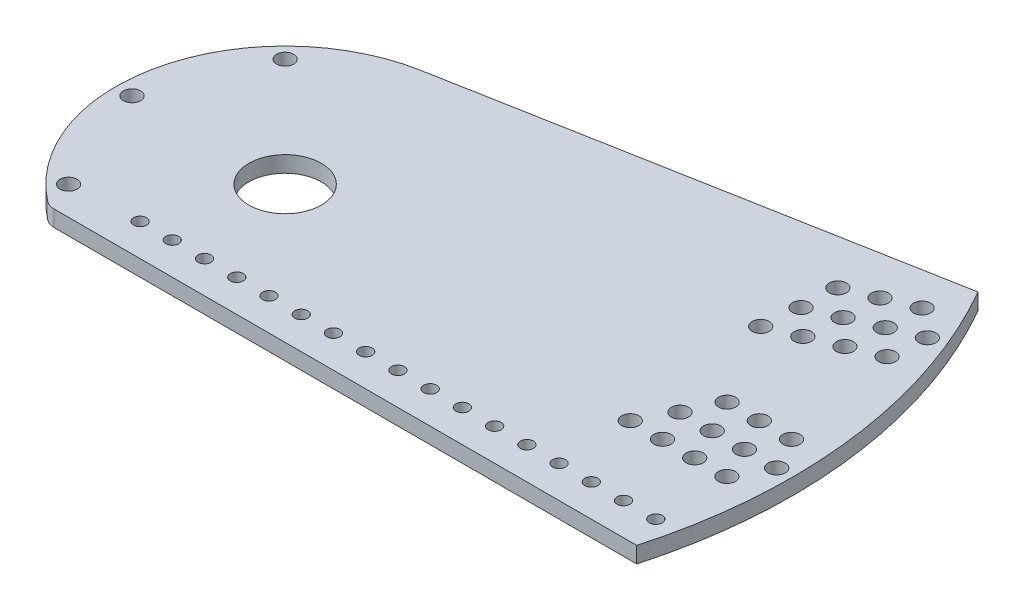
from build123d import *

# Parameters (mm, degrees)
SKETCH1_R           = 3.3782
SKETCH1_R_2         = 14.28115
SKETCH1_R_3         = 2.5527
SKETCH1_R_4         = 9.5885
SKETCH1_R_5         = 19.177
SKETCH1_R_6         = 4.1275
BOSS_EXTRUDE1_DEPTH = 6.35
SKETCH2_R           = 19.177
SKETCH2_R_2         = 2.5527
SKETCH2_R_3         = 4.1275
SKETCH2_R_4         = 9.5885
BOSS_EXTRUDE2_DEPTH = 6.35
CUT_EXTRUDE1_DEPTH  = 337.819467594
BOSS_EXTRUDE3_DEPTH = 6.35


with BuildPart() as part:
    # Sketch1 → Boss-Extrude1 (new body)
    with BuildSketch(Plane.XZ):
        with BuildLine():
            Line((231.775, 53.975), (-37.026544532, 53.975))
            ThreePointArc((-37.026544532, 53.975), (-39.086756581, 53.631498674), (-40.924075536, 52.638157895))
            ThreePointArc((-40.924075536, 52.638157895), (-66.304119268, -7.022776738), (-28.989130435, -60.043200628))
            ThreePointArc((-28.989130435, -60.043200628), (-26.371616333, -62.385880153), (-25.4, -65.761600688))
            Line((-25.4, -65.761600688), (-25.4, -230.990796624))
            ThreePointArc((-25.4, -230.990796624), (-23.721010495, -235.292442932), (-19.571917808, -237.3193116))
            ThreePointArc((-19.571917808, -237.3193116), (161.311736549, -175.162893549), (238.125, 0))
            Line((238.125, 0), (238.125, 47.625))
            ThreePointArc((238.125, 47.625), (236.265128061, 52.115128061), (231.775, 53.975))
        make_face()
        with Locations(Location((-60.325, 0, 0), (0, 0, 90))):
            Circle(SKETCH1_R, mode=Mode.SUBTRACT)
        with Locations(Location((-42.656216575, 42.656216575, 0), (0, 0, 90))):
            Circle(SKETCH1_R, mode=Mode.SUBTRACT)
        with Locations(Location((-42.656216575, -42.656216575, 0), (0, 0, 90))):
            Circle(SKETCH1_R, mode=Mode.SUBTRACT)
        with Locations(Location((0, -155.575, 0), (0, 0, 90))):
            Circle(SKETCH1_R, mode=Mode.SUBTRACT)
        with Locations(Location((0, -168.275, 0), (0, 0, 90))):
            Circle(SKETCH1_R, mode=Mode.SUBTRACT)
        with Locations(Location((0, -180.975, 0), (0, 0, 90))):
            Circle(SKETCH1_R, mode=Mode.SUBTRACT)
        with Locations(Location((0, -193.675, 0), (0, 0, 90))):
            Circle(SKETCH1_R, mode=Mode.SUBTRACT)
        with Locations(Location((0, -206.375, 0), (0, 0, 90))):
            Circle(SKETCH1_R, mode=Mode.SUBTRACT)
        with Locations(Location((0, -219.075, 0), (0, 0, 90))):
            Circle(SKETCH1_R, mode=Mode.SUBTRACT)
        with Locations(Location((59.53597499, -143.73255827, 0), (0, 0, 90))):
            Circle(SKETCH1_R, mode=Mode.SUBTRACT)
        with Locations(Location((64.396054581, -155.465828333, 0), (0, 0, 90))):
            Circle(SKETCH1_R, mode=Mode.SUBTRACT)
        with Locations(Location((69.256134172, -167.199098396, 0), (0, 0, 90))):
            Circle(SKETCH1_R, mode=Mode.SUBTRACT)
        with Locations(Location((74.116213763, -178.932368459, 0), (0, 0, 90))):
            Circle(SKETCH1_R, mode=Mode.SUBTRACT)
        with Locations(Location((78.976293354, -190.665638522, 0), (0, 0, 90))):
            Circle(SKETCH1_R, mode=Mode.SUBTRACT)
        with Locations(Location((83.836372945, -202.398908585, 0), (0, 0, 90))):
            Circle(SKETCH1_R, mode=Mode.SUBTRACT)
        with Locations(Location((110.008137483, -110.008137483, 0), (0, 0, 90))):
            Circle(SKETCH1_R, mode=Mode.SUBTRACT)
        with Locations(Location((118.988393604, -118.988393604, 0), (0, 0, 90))):
            Circle(SKETCH1_R, mode=Mode.SUBTRACT)
        with Locations(Location((127.968649725, -127.968649725, 0), (0, 0, 90))):
            Circle(SKETCH1_R, mode=Mode.SUBTRACT)
        with Locations(Location((136.948905846, -136.948905846, 0), (0, 0, 90))):
            Circle(SKETCH1_R, mode=Mode.SUBTRACT)
        with Locations(Location((145.929161967, -145.929161967, 0), (0, 0, 90))):
            Circle(SKETCH1_R, mode=Mode.SUBTRACT)
        with Locations(Location((154.909418088, -154.909418088, 0), (0, 0, 90))):
            Circle(SKETCH1_R, mode=Mode.SUBTRACT)
        with Locations(Location((143.73255827, -59.53597499, 0), (0, 0, 90))):
            Circle(SKETCH1_R, mode=Mode.SUBTRACT)
        with Locations(Location((155.465828333, -64.396054581, 0), (0, 0, 90))):
            Circle(SKETCH1_R, mode=Mode.SUBTRACT)
        with Locations(Location((167.199098396, -69.256134172, 0), (0, 0, 90))):
            Circle(SKETCH1_R, mode=Mode.SUBTRACT)
        with Locations(Location((178.932368459, -74.116213763, 0), (0, 0, 90))):
            Circle(SKETCH1_R, mode=Mode.SUBTRACT)
        with Locations(Location((190.665638522, -78.976293354, 0), (0, 0, 90))):
            Circle(SKETCH1_R, mode=Mode.SUBTRACT)
        with Locations(Location((202.398908585, -83.836372945, 0), (0, 0, 90))):
            Circle(SKETCH1_R, mode=Mode.SUBTRACT)
        with Locations(Location((155.575, 0, 0), (0, 0, 90))):
            Circle(SKETCH1_R, mode=Mode.SUBTRACT)
        with Locations(Location((168.275, 0, 0), (0, 0, 90))):
            Circle(SKETCH1_R, mode=Mode.SUBTRACT)
        with Locations(Location((180.975, 0, 0), (0, 0, 90))):
            Circle(SKETCH1_R, mode=Mode.SUBTRACT)
        with Locations(Location((193.675, 0, 0), (0, 0, 90))):
            Circle(SKETCH1_R, mode=Mode.SUBTRACT)
        with Locations(Location((206.375, 0, 0), (0, 0, 90))):
            Circle(SKETCH1_R, mode=Mode.SUBTRACT)
        with Locations(Location((219.075, 0, 0), (0, 0, 90))):
            Circle(SKETCH1_R, mode=Mode.SUBTRACT)
        with Locations(Location((0, 0, 0), (0, 0, 90))):
            Circle(SKETCH1_R_2, mode=Mode.SUBTRACT)
        with Locations(Location((148.683592319, 12.7, 0), (0, 0, 90))):
            Circle(SKETCH1_R, mode=Mode.SUBTRACT)
        with Locations(Location((141.086323741, -159.046835983, 0), (0, 0, 90))):
            Circle(SKETCH1_R, mode=Mode.SUBTRACT)
        with Locations(Location((150.036456986, -132.075944743, 0), (0, 0, 90))):
            Circle(SKETCH1_R, mode=Mode.SUBTRACT)
        with Locations(Location((150.066579862, -168.027092104, 0), (0, 0, 90))):
            Circle(SKETCH1_R, mode=Mode.SUBTRACT)
        with Locations(Location((159.016713107, -141.056200864, 0), (0, 0, 90))):
            Circle(SKETCH1_R, mode=Mode.SUBTRACT)
        with Locations(Location((-12.7, -186.8261925, 0), (0, 0, 90))):
            Circle(SKETCH1_R, mode=Mode.SUBTRACT)
        with Locations(Location((12.7, -174.083592319, 0), (0, 0, 90))):
            Circle(SKETCH1_R, mode=Mode.SUBTRACT)
        with Locations(Location((-12.7, -199.5261925, 0), (0, 0, 90))):
            Circle(SKETCH1_R, mode=Mode.SUBTRACT)
        with Locations(Location((12.7, -186.783592319, 0), (0, 0, 90))):
            Circle(SKETCH1_R, mode=Mode.SUBTRACT)
        with Locations(Location((-12.7, -212.2261925, 0), (0, 0, 90))):
            Circle(SKETCH1_R, mode=Mode.SUBTRACT)
        with Locations(Location((12.7, -199.483592319, 0), (0, 0, 90))):
            Circle(SKETCH1_R, mode=Mode.SUBTRACT)
        with Locations(Location((-12.7, -224.9261925, 0), (0, 0, 90))):
            Circle(SKETCH1_R, mode=Mode.SUBTRACT)
        with Locations(Location((12.7, -212.183592319, 0), (0, 0, 90))):
            Circle(SKETCH1_R, mode=Mode.SUBTRACT)
        with Locations(Location((69.482177721, -200.931515104, 0), (0, 0, 90))):
            Circle(SKETCH1_R, mode=Mode.SUBTRACT)
        with Locations(Location((88.072335872, -179.438728425, 0), (0, 0, 90))):
            Circle(SKETCH1_R, mode=Mode.SUBTRACT)
        with Locations(Location((74.342257312, -212.664785167, 0), (0, 0, 90))):
            Circle(SKETCH1_R, mode=Mode.SUBTRACT)
        with Locations(Location((92.932415463, -191.171998488, 0), (0, 0, 90))):
            Circle(SKETCH1_R, mode=Mode.SUBTRACT)
        with Locations(Location((50.041859357, -153.998434853, 0), (0, 0, 90))):
            Circle(SKETCH1_R, mode=Mode.SUBTRACT)
        with Locations(Location((68.632017508, -132.505648173, 0), (0, 0, 90))):
            Circle(SKETCH1_R, mode=Mode.SUBTRACT)
        with Locations(Location((54.901938948, -165.731704916, 0), (0, 0, 90))):
            Circle(SKETCH1_R, mode=Mode.SUBTRACT)
        with Locations(Location((73.492097099, -144.238918236, 0), (0, 0, 90))):
            Circle(SKETCH1_R, mode=Mode.SUBTRACT)
        with Locations(Location((59.762018539, -177.464974979, 0), (0, 0, 90))):
            Circle(SKETCH1_R, mode=Mode.SUBTRACT)
        with Locations(Location((78.35217669, -155.972188299, 0), (0, 0, 90))):
            Circle(SKETCH1_R, mode=Mode.SUBTRACT)
        with Locations(Location((64.62209813, -189.198245042, 0), (0, 0, 90))):
            Circle(SKETCH1_R, mode=Mode.SUBTRACT)
        with Locations(Location((83.212256281, -167.705458362, 0), (0, 0, 90))):
            Circle(SKETCH1_R, mode=Mode.SUBTRACT)
        with Locations(Location((123.125811499, -141.086323741, 0), (0, 0, 90))):
            Circle(SKETCH1_R, mode=Mode.SUBTRACT)
        with Locations(Location((132.075944743, -114.115432501, 0), (0, 0, 90))):
            Circle(SKETCH1_R, mode=Mode.SUBTRACT)
        with Locations(Location((132.10606762, -150.066579862, 0), (0, 0, 90))):
            Circle(SKETCH1_R, mode=Mode.SUBTRACT)
        with Locations(Location((141.056200864, -123.095688622, 0), (0, 0, 90))):
            Circle(SKETCH1_R, mode=Mode.SUBTRACT)
        with Locations(Location((200.89215767, -69.465875337, 0), (0, 0, 90))):
            Circle(SKETCH1_R, mode=Mode.SUBTRACT)
        with Locations(Location((202.944625985, -97.808797438, 0), (0, 0, 90))):
            Circle(SKETCH1_R, mode=Mode.SUBTRACT)
        with Locations(Location((189.158887607, -64.605795746, 0), (0, 0, 90))):
            Circle(SKETCH1_R, mode=Mode.SUBTRACT)
        with Locations(Location((191.211355922, -92.948717847, 0), (0, 0, 90))):
            Circle(SKETCH1_R, mode=Mode.SUBTRACT)
        with Locations(Location((105.165299257, -123.125811499, 0), (0, 0, 90))):
            Circle(SKETCH1_R, mode=Mode.SUBTRACT)
        with Locations(Location((114.115432501, -96.154920259, 0), (0, 0, 90))):
            Circle(SKETCH1_R, mode=Mode.SUBTRACT)
        with Locations(Location((114.145555378, -132.10606762, 0), (0, 0, 90))):
            Circle(SKETCH1_R, mode=Mode.SUBTRACT)
        with Locations(Location((123.095688622, -105.13517638, 0), (0, 0, 90))):
            Circle(SKETCH1_R, mode=Mode.SUBTRACT)
        with Locations(Location((153.959077418, -50.025556973, 0), (0, 0, 90))):
            Circle(SKETCH1_R, mode=Mode.SUBTRACT)
        with Locations(Location((156.011545734, -78.368479073, 0), (0, 0, 90))):
            Circle(SKETCH1_R, mode=Mode.SUBTRACT)
        with Locations(Location((142.225807355, -45.165477382, 0), (0, 0, 90))):
            Circle(SKETCH1_R, mode=Mode.SUBTRACT)
        with Locations(Location((144.278275671, -73.508399482, 0), (0, 0, 90))):
            Circle(SKETCH1_R, mode=Mode.SUBTRACT)
        with Locations(Location((177.425617544, -59.745716155, 0), (0, 0, 90))):
            Circle(SKETCH1_R, mode=Mode.SUBTRACT)
        with Locations(Location((179.478085859, -88.088638255, 0), (0, 0, 90))):
            Circle(SKETCH1_R, mode=Mode.SUBTRACT)
        with Locations(Location((165.692347481, -54.885636564, 0), (0, 0, 90))):
            Circle(SKETCH1_R, mode=Mode.SUBTRACT)
        with Locations(Location((167.744815797, -83.228558664, 0), (0, 0, 90))):
            Circle(SKETCH1_R, mode=Mode.SUBTRACT)
        with Locations(Location((-12.7, -161.4261925, 0), (0, 0, 90))):
            Circle(SKETCH1_R, mode=Mode.SUBTRACT)
        with Locations(Location((12.7, -148.683592319, 0), (0, 0, 90))):
            Circle(SKETCH1_R, mode=Mode.SUBTRACT)
        with Locations(Location((-12.7, -174.1261925, 0), (0, 0, 90))):
            Circle(SKETCH1_R, mode=Mode.SUBTRACT)
        with Locations(Location((12.7, -161.383592319, 0), (0, 0, 90))):
            Circle(SKETCH1_R, mode=Mode.SUBTRACT)
        with Locations(Location((186.8261925, -12.7, 0), (0, 0, 90))):
            Circle(SKETCH1_R, mode=Mode.SUBTRACT)
        with Locations(Location((174.083592319, 12.7, 0), (0, 0, 90))):
            Circle(SKETCH1_R, mode=Mode.SUBTRACT)
        with Locations(Location((199.5261925, -12.7, 0), (0, 0, 90))):
            Circle(SKETCH1_R, mode=Mode.SUBTRACT)
        with Locations(Location((186.783592319, 12.7, 0), (0, 0, 90))):
            Circle(SKETCH1_R, mode=Mode.SUBTRACT)
        with Locations(Location((212.2261925, -12.7, 0), (0, 0, 90))):
            Circle(SKETCH1_R, mode=Mode.SUBTRACT)
        with Locations(Location((199.483592319, 12.7, 0), (0, 0, 90))):
            Circle(SKETCH1_R, mode=Mode.SUBTRACT)
        with Locations(Location((224.9261925, -12.7, 0), (0, 0, 90))):
            Circle(SKETCH1_R, mode=Mode.SUBTRACT)
        with Locations(Location((212.183592319, 12.7, 0), (0, 0, 90))):
            Circle(SKETCH1_R, mode=Mode.SUBTRACT)
        with Locations(Location((161.4261925, -12.7, 0), (0, 0, 90))):
            Circle(SKETCH1_R, mode=Mode.SUBTRACT)
        with Locations(Location((174.1261925, -12.7, 0), (0, 0, 90))):
            Circle(SKETCH1_R, mode=Mode.SUBTRACT)
        with Locations(Location((161.383592319, 12.7, 0), (0, 0, 90))):
            Circle(SKETCH1_R, mode=Mode.SUBTRACT)
        with Locations(Location((225.425, 41.275, 0), (0, 0, 90))):
            Circle(SKETCH1_R_3, mode=Mode.SUBTRACT)
        with Locations(Location((212.725, 41.275, 0), (0, 0, 90))):
            Circle(SKETCH1_R_3, mode=Mode.SUBTRACT)
        with Locations(Location((200.025, 41.275, 0), (0, 0, 90))):
            Circle(SKETCH1_R_3, mode=Mode.SUBTRACT)
        with Locations(Location((187.325, 41.275, 0), (0, 0, 90))):
            Circle(SKETCH1_R_3, mode=Mode.SUBTRACT)
        with Locations(Location((174.625, 41.275, 0), (0, 0, 90))):
            Circle(SKETCH1_R_3, mode=Mode.SUBTRACT)
        with Locations(Location((161.925, 41.275, 0), (0, 0, 90))):
            Circle(SKETCH1_R_3, mode=Mode.SUBTRACT)
        with Locations(Location((149.225, 41.275, 0), (0, 0, 90))):
            Circle(SKETCH1_R_3, mode=Mode.SUBTRACT)
        with Locations(Location((136.525, 41.275, 0), (0, 0, 90))):
            Circle(SKETCH1_R_3, mode=Mode.SUBTRACT)
        with Locations(Location((123.825, 41.275, 0), (0, 0, 90))):
            Circle(SKETCH1_R_3, mode=Mode.SUBTRACT)
        with Locations(Location((111.125, 41.275, 0), (0, 0, 90))):
            Circle(SKETCH1_R_3, mode=Mode.SUBTRACT)
        with Locations(Location((98.425, 41.275, 0), (0, 0, 90))):
            Circle(SKETCH1_R_3, mode=Mode.SUBTRACT)
        with Locations(Location((73.025, 41.275, 0), (0, 0, 90))):
            Circle(SKETCH1_R_3, mode=Mode.SUBTRACT)
        with Locations(Location((85.725, 41.275, 0), (0, 0, 90))):
            Circle(SKETCH1_R_3, mode=Mode.SUBTRACT)
        with Locations(Location((60.325, 41.275, 0), (0, 0, 90))):
            Circle(SKETCH1_R_3, mode=Mode.SUBTRACT)
        with Locations(Location((47.625, 41.275, 0), (0, 0, 90))):
            Circle(SKETCH1_R_3, mode=Mode.SUBTRACT)
        with Locations(Location((34.925, 41.275, 0), (0, 0, 90))):
            Circle(SKETCH1_R_3, mode=Mode.SUBTRACT)
        with Locations(Location((22.225, 41.275, 0), (0, 0, 90))):
            Circle(SKETCH1_R_3, mode=Mode.SUBTRACT)
        with Locations(Location((9.525, 41.275, 0), (0, 0, 90))):
            Circle(SKETCH1_R_3, mode=Mode.SUBTRACT)
        with Locations(Location((-3.175, 41.275, 0), (0, 0, 90))):
            Circle(SKETCH1_R_3, mode=Mode.SUBTRACT)
        with Locations(Location((-15.875, 41.275, 0), (0, 0, 90))):
            Circle(SKETCH1_R_3, mode=Mode.SUBTRACT)
        with Locations(Location((-17.960512242, 17.960512242, 0), (0, 0, 90))):
            Circle(SKETCH1_R_3, mode=Mode.SUBTRACT)
        with Locations(Location((-17.960512242, -17.960512242, 0), (0, 0, 90))):
            Circle(SKETCH1_R_3, mode=Mode.SUBTRACT)
        with Locations(Location((17.960512242, -17.960512242, 0), (0, 0, 90))):
            Circle(SKETCH1_R_3, mode=Mode.SUBTRACT)
        with Locations(Location((17.960512242, 17.960512242, 0), (0, 0, 90))):
            Circle(SKETCH1_R_3, mode=Mode.SUBTRACT)
        with Locations(Location((52.114561305, -6.35, 0), (0, 0, 90))):
            Circle(SKETCH1_R_4, mode=Mode.SUBTRACT)
        with Locations(Location((70.075073547, 11.610512242, 0), (0, 0, 90))):
            Circle(SKETCH1_R_3, mode=Mode.SUBTRACT)
        with Locations(Location((-17.960512242, -34.539487758, 0), (0, 0, 90))):
            Circle(SKETCH1_R_3, mode=Mode.SUBTRACT)
        with Locations(Location((17.960512242, -70.460512242, 0), (0, 0, 90))):
            Circle(SKETCH1_R_3, mode=Mode.SUBTRACT)
        with Locations(Location((70.075073547, -24.310512242, 0), (0, 0, 90))):
            Circle(SKETCH1_R_3, mode=Mode.SUBTRACT)
        with Locations(Location((34.154049063, -24.310512242, 0), (0, 0, 90))):
            Circle(SKETCH1_R_3, mode=Mode.SUBTRACT)
        with Locations(Location((34.154049063, 11.610512242, 0), (0, 0, 90))):
            Circle(SKETCH1_R_3, mode=Mode.SUBTRACT)
        with Locations(Location((0, -52.5, 0), (0, 0, 90))):
            Circle(SKETCH1_R_5, mode=Mode.SUBTRACT)
        with Locations(Location((-17.960512242, -70.460512242, 0), (0, 0, 90))):
            Circle(SKETCH1_R_6, mode=Mode.SUBTRACT)
        with Locations(Location((17.960512242, -34.539487758, 0), (0, 0, 90))):
            Circle(SKETCH1_R_6, mode=Mode.SUBTRACT)
    extrude(amount=-BOSS_EXTRUDE1_DEPTH)

    # Sketch2 → Boss-Extrude2 (add, through all)
    with BuildSketch(Plane(origin=(0, 6.35, 0), x_dir=(1, 0, 0), z_dir=(0, 1, 0))):
        with Locations((0, 52.5)):
            Circle(SKETCH2_R)
        with Locations((17.960512242, 70.460512242)):
            Circle(SKETCH2_R_2)
        with Locations((17.960512242, 34.539487758)):
            Circle(SKETCH2_R_3)
        with Locations((-17.960512242, 34.539487758)):
            Circle(SKETCH2_R_2)
        with Locations((-17.960512242, 70.460512242)):
            Circle(SKETCH2_R_3)
        with Locations((34.154049063, -11.610512242)):
            Circle(SKETCH2_R_2)
        with Locations((52.114561305, 6.35)):
            Circle(SKETCH2_R_4)
        with Locations((34.154049063, 24.310512242)):
            Circle(SKETCH2_R_2)
        with Locations((70.075073547, 24.310512242)):
            Circle(SKETCH2_R_2)
        with Locations((70.075073547, -11.610512242)):
            Circle(SKETCH2_R_2)
        with Locations((17.960512242, -17.960512242)):
            Circle(SKETCH2_R_2)
        with Locations((-17.960512242, -17.960512242)):
            Circle(SKETCH2_R_2)
        with Locations((-17.960512242, 17.960512242)):
            Circle(SKETCH2_R_2)
        with Locations((17.960512242, 17.960512242)):
            Circle(SKETCH2_R_2)
    extrude(amount=-BOSS_EXTRUDE2_DEPTH)

    # Sketch3 → Cut-Extrude1 (cut, through all)
    with BuildSketch(Plane(origin=(0, 6.35, 0), x_dir=(1, 0, 0), z_dir=(0, 1, 0))):
        with BuildLine():
            Line((-28.989130435, 60.043200628), (-28.989130435, 240.201050618))
            Line((-28.989130435, 240.201050618), (143.888334306, 240.201050618))
            Line((143.888334306, 240.201050618), (143.888334306, 195.6215824))
            ThreePointArc((143.888334306, 195.6215824), (221.363286109, 99.849646033), (241.876866839, -21.615678064))
            Line((241.876866839, -21.615678064), (241.876866839, -61.19292902))
            Line((241.876866839, -61.19292902), (235.004429082, -61.19292902))
            Line((235.004429082, -61.19292902), (190.335012364, -61.19292902))
            ThreePointArc((190.335012364, -61.19292902), (198.816818934, 21.068080183), (173.283022861, 99.72454804))
            Line((173.283022861, 99.72454804), (-12.081458079, 65.571289416))
            ThreePointArc((-12.081458079, 65.571289416), (-20.720479039, 63.373633109), (-28.989130435, 60.043200628))
        make_face()
    extrude(amount=-CUT_EXTRUDE1_DEPTH, mode=Mode.SUBTRACT)

    # Sketch4 → Boss-Extrude3 (add)
    with BuildSketch(Plane(origin=(0, 6.35, 0), x_dir=(1, 0, 0), z_dir=(0, 1, 0))):
        with BuildLine():
            ThreePointArc((199.712292742, 9.326929894), (199.5261925, 12.7), (199.283126373, 16.069444182))
            ThreePointArc((199.283126373, 16.069444182), (196.154815035, 12.485409157), (199.712292742, 9.326929894))
        make_face()
        with BuildLine():
            ThreePointArc((188.080248089, 67.807166083), (185.962005828, 63.513924813), (190.263971279, 61.413457212))
            ThreePointArc((190.263971279, 61.413457212), (189.199119873, 64.619536774), (188.080248089, 67.807166083))
        make_face()
        with BuildLine():
            ThreePointArc((180.94083811, 85.043545302), (179.478085859, 88.088638255), (177.964091575, 91.108581392))
            ThreePointArc((177.964091575, 91.108581392), (176.445459584, 86.600211868), (180.94083811, 85.043545302))
        make_face()
        with BuildLine():
            ThreePointArc((199.282901438, -16.072233445), (199.52602055, -12.702701167), (199.712170735, -9.329541997))
            ThreePointArc((199.712170735, -9.329541997), (196.11221776, -12.485363516), (199.282901438, -16.072233445))
        make_face()
    extrude(amount=-BOSS_EXTRUDE3_DEPTH)


solid = part.part
